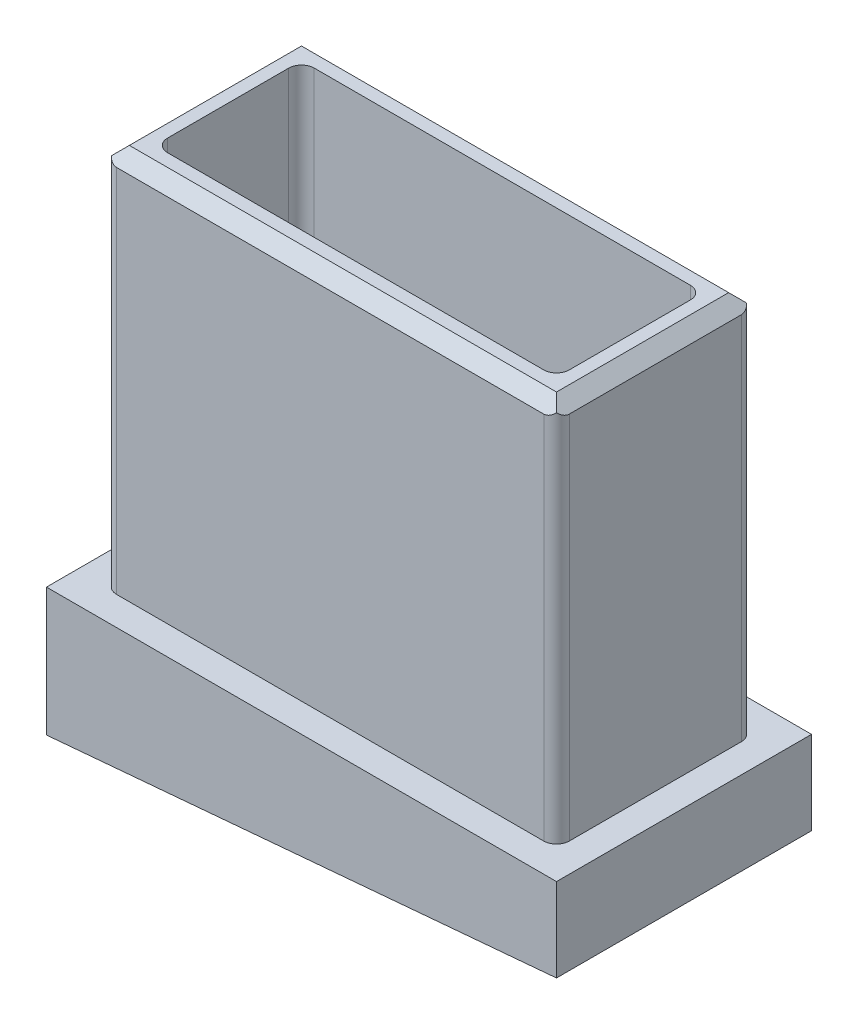
from build123d import *

# Parameters (mm, degrees)
SKETCH1_W           = 45.085
SKETCH1_H           = 38.1
BOSS_EXTRUDE1_DEPTH = 9.8425
SKETCH2_W           = 50.8
SKETCH2_H           = 25.4
BOSS_EXTRUDE2_DEPTH = 12.7635
CUT_EXTRUDE1_DEPTH  = 26.4
SKETCH4_W           = 40.005
SKETCH4_H           = 14.605
CUT_EXTRUDE2_DEPTH  = 38.1
CHAMFER1_SIZE       = 1.27
FILLET1_R           = 1.27


with BuildPart() as part:
    # Sketch1 → Boss-Extrude1 (new body, symmetric)
    with BuildSketch(Plane.XY):
        Rectangle(SKETCH1_W, SKETCH1_H)
    extrude(amount=BOSS_EXTRUDE1_DEPTH, both=True)

    # Sketch2 → Boss-Extrude2 (add)
    with BuildSketch(Plane.XZ.offset(19.05)):
        Rectangle(SKETCH2_W, SKETCH2_H)
    extrude(amount=BOSS_EXTRUDE2_DEPTH)

    # Sketch3 → Cut-Extrude1 (cut, through all)
    with BuildSketch(Plane.XY.offset(12.7)):
        Polygon((25.4, -31.8135), (25.4, -27.369075893), (-25.4, -31.8135), align=None)
    extrude(amount=-CUT_EXTRUDE1_DEPTH, mode=Mode.SUBTRACT)

    # Sketch4 → Cut-Extrude2 (cut)
    with BuildSketch(Plane(origin=(0, 19.05, 0), x_dir=(1, 0, 0), z_dir=(0, 1, 0))):
        Rectangle(SKETCH4_W, SKETCH4_H)
    extrude(amount=-CUT_EXTRUDE2_DEPTH, mode=Mode.SUBTRACT)

    # Chamfer1
    chamfer1_edges = [part.edges().sort_by_distance(p)[0] for p in [
        (0, 19.05, -9.8425),
        (-22.5425, 19.05, 0),
        (22.5425, 19.05, 0),
        (0, 19.05, 9.8425),
    ]]
    chamfer(chamfer1_edges, length=CHAMFER1_SIZE)

    # Fillet1
    fillet1_edges = [part.edges().sort_by_distance(p)[0] for p in [
        (20.0025, 0, -7.3025),
        (20.0025, 0, 7.3025),
        (-20.0025, 0, 7.3025),
        (-20.0025, 0, -7.3025),
        (22.5425, -0.635, 9.8425),
        (-22.5425, -0.635, -9.8425),
        (-22.5425, -0.635, 9.8425),
        (22.5425, -0.635, -9.8425),
    ]]
    fillet(fillet1_edges, radius=FILLET1_R)


solid = part.part
